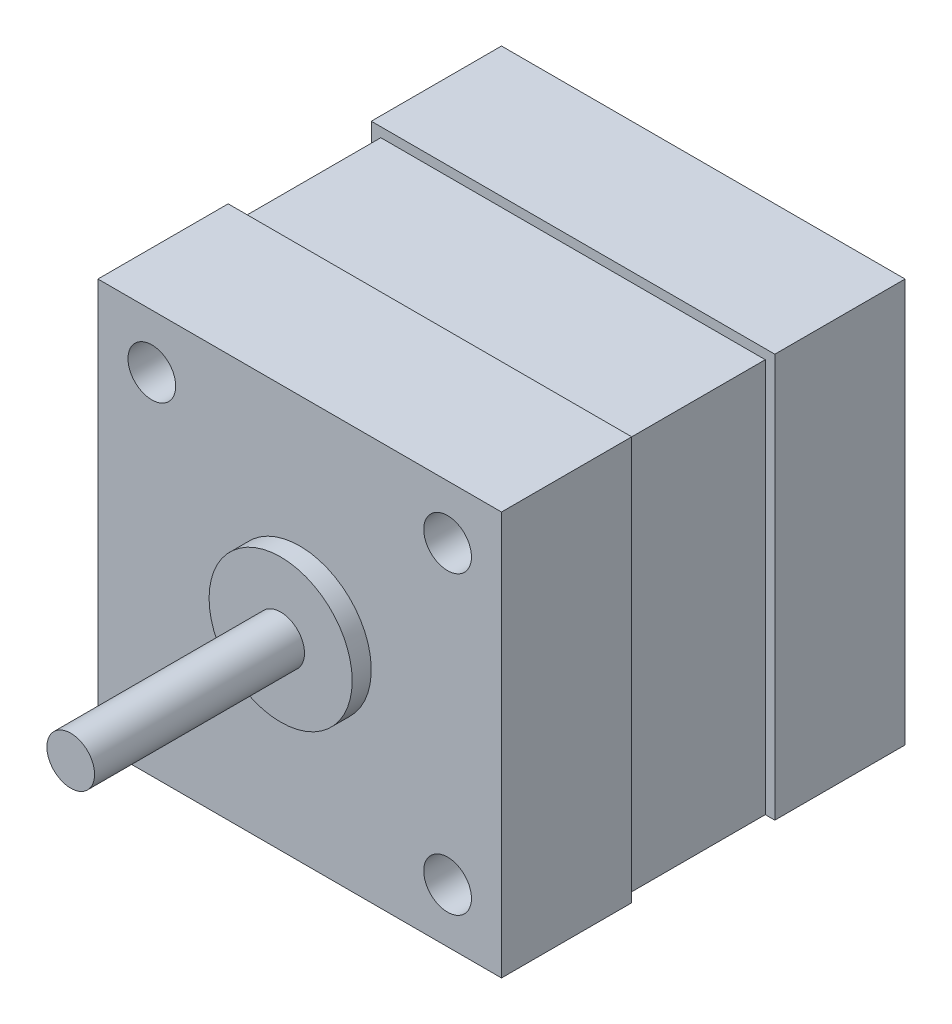
from build123d import *

# Parameters (mm, degrees)
SKETCH1_W           = 42.3
SKETCH1_H           = 42.3
SKETCH1_R           = 2.5
BOSS_EXTRUDE1_DEPTH = 42.3
SKETCH2_R           = 2.5
BOSS_EXTRUDE2_DEPTH = 24
SKETCH3_R           = 7.5
BOSS_EXTRUDE3_DEPTH = 2
SKETCH4_W           = 15
SKETCH4_H           = 42.3
CUT_EXTRUDE1_DEPTH  = 1
SKETCH5_W           = 41.3
SKETCH5_H           = 15
CUT_EXTRUDE2_DEPTH  = 1


with BuildPart() as part:
    # Sketch1 → Boss-Extrude1 (new body)
    with BuildSketch(Plane.XY):
        Rectangle(SKETCH1_W, SKETCH1_H)
        with Locations((-15.5, 15.5)):
            Circle(SKETCH1_R, mode=Mode.SUBTRACT)
        with Locations((15.5, 15.5)):
            Circle(SKETCH1_R, mode=Mode.SUBTRACT)
        with Locations((15.5, -15.5)):
            Circle(SKETCH1_R, mode=Mode.SUBTRACT)
        with Locations((-15.5, -15.5)):
            Circle(SKETCH1_R, mode=Mode.SUBTRACT)
    extrude(amount=BOSS_EXTRUDE1_DEPTH)

    # Sketch2 → Boss-Extrude2 (add)
    with BuildSketch(Plane.XY.offset(42.3)):
        Circle(SKETCH2_R)
    extrude(amount=BOSS_EXTRUDE2_DEPTH)

    # Sketch3 → Boss-Extrude3 (add)
    with BuildSketch(Plane.XY.offset(42.3)):
        Circle(SKETCH3_R)
    extrude(amount=BOSS_EXTRUDE3_DEPTH)

    # Sketch4 → Cut-Extrude1 (cut)
    with BuildSketch(Plane(origin=(21.15, 0, 0), x_dir=(0, 0, -1), z_dir=(1, 0, 0))):
        with Locations((-21.15, 0)):
            Rectangle(SKETCH4_W, SKETCH4_H)
    cut_extrude1 = extrude(amount=-CUT_EXTRUDE1_DEPTH, mode=Mode.SUBTRACT)

    # Sketch5 → Cut-Extrude2 (cut)
    with BuildSketch(Plane(origin=(0, 21.15, 0), x_dir=(1, 0, 0), z_dir=(0, 1, 0))):
        with Locations((-0.5, -21.15)):
            Rectangle(SKETCH5_W, SKETCH5_H)
    extrude(amount=-CUT_EXTRUDE2_DEPTH, mode=Mode.SUBTRACT)

    # Mirror1: Cut-Extrude1 across plane
    add(cut_extrude1.mirror(Plane(origin=(0, 0, 0), x_dir=(0, 0, 1), z_dir=(1, 0, 0))), mode=Mode.SUBTRACT)


solid = part.part
